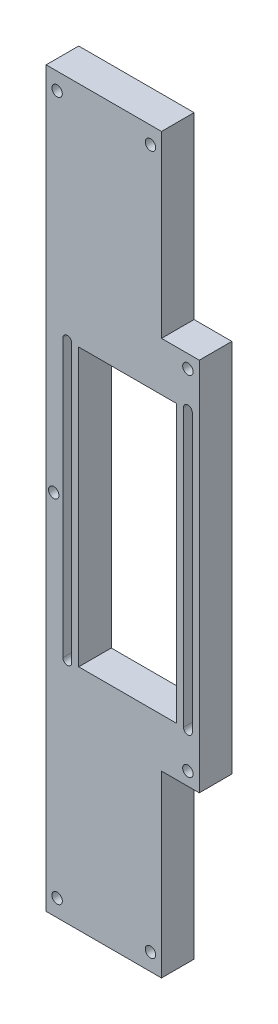
from build123d import *

# Parameters (mm, degrees)
SKETCH4_R           = 1.6
SKETCH4_W           = 30
SKETCH4_H           = 85
BOSS_EXTRUDE6_DEPTH = 10


with BuildPart() as part:
    # Sketch4 → Boss-Extrude6 (new body)
    with BuildSketch(Plane.XY):
        Polygon((-109.544479684, 259.95267573), (-74.140420057, 259.95267573), (-74.140420057, 204.95267573), (-62.544479684, 204.95267573), (-62.544479684, 89.95267573), (-74.140420057, 89.95267573), (-74.140420057, 34.95267573), (-109.544479684, 34.95267573), align=None)
        with Locations((-77.519250358, 254.723971913)):
            Circle(SKETCH4_R, mode=Mode.SUBTRACT)
        with Locations((-106.178709835, 40.181379546)):
            Circle(SKETCH4_R, mode=Mode.SUBTRACT)
        with Locations((-77.519250358, 40.181379546)):
            Circle(SKETCH4_R, mode=Mode.SUBTRACT)
        with Locations((-66.044479684, 94.019745429)):
            Circle(SKETCH4_R, mode=Mode.SUBTRACT)
        with Locations((-107.209755901, 147.45267573)):
            Circle(SKETCH4_R, mode=Mode.SUBTRACT)
        with Locations((-66.044479684, 200.885606031)):
            Circle(SKETCH4_R, mode=Mode.SUBTRACT)
        with Locations((-106.178709835, 254.723971913)):
            Circle(SKETCH4_R, mode=Mode.SUBTRACT)
        with Locations((-84.544479684, 147.45267573)):
            Rectangle(SKETCH4_W, SKETCH4_H, mode=Mode.SUBTRACT)
        with BuildLine():
            Line((-67.394479684, 189.95267573), (-67.394479684, 147.45267573))
            Line((-67.394479684, 147.45267573), (-67.394479684, 104.95267573))
            ThreePointArc((-67.394479684, 104.95267573), (-66.044479684, 103.60267573), (-64.694479684, 104.95267573))
            Line((-64.694479684, 104.95267573), (-64.694479684, 147.45267573))
            Line((-64.694479684, 147.45267573), (-64.694479684, 189.95267573))
            ThreePointArc((-64.694479684, 189.95267573), (-66.044479684, 191.30267573), (-67.394479684, 189.95267573))
        make_face(mode=Mode.SUBTRACT)
        with BuildLine():
            Line((-104.394479684, 189.95267573), (-104.394479684, 147.45267573))
            Line((-104.394479684, 147.45267573), (-104.394479684, 104.95267573))
            ThreePointArc((-104.394479684, 104.95267573), (-103.044479684, 103.60267573), (-101.694479684, 104.95267573))
            Line((-101.694479684, 104.95267573), (-101.694479684, 147.45267573))
            Line((-101.694479684, 147.45267573), (-101.694479684, 189.95267573))
            ThreePointArc((-101.694479684, 189.95267573), (-103.044479684, 191.30267573), (-104.394479684, 189.95267573))
        make_face(mode=Mode.SUBTRACT)
    extrude(amount=BOSS_EXTRUDE6_DEPTH)


solid = part.part
